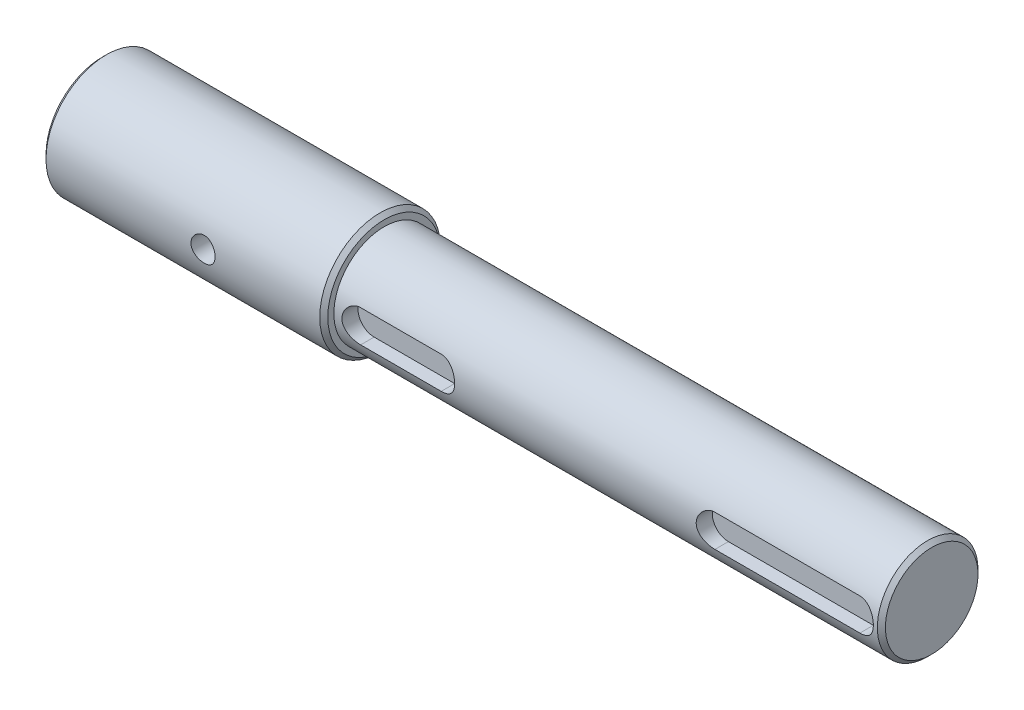
from build123d import *

# Parameters (mm, degrees)
SKETCH_1_R               = 12.5
EXTRUDE_1_DEPTH          = 136
SKETCH_2_R               = 15
EXTRUDE_2_DEPTH          = 70
CHAMFER_1_SIZE           = 1
CUT_EXTRUDE_1_DEPTH      = 4
SKETCH_4_R               = 3
CUT_EXTRUDE_2_DEPTH      = 16
CUT_EXTRUDE_2_DEPTH_BACK = 16


with BuildPart() as part:
    # 草图1 → 凸台-拉伸1 (new body)
    with BuildSketch(Plane(origin=(0, 0, 0), x_dir=(0, 0, -1), z_dir=(1, 0, 0))):
        Circle(SKETCH_1_R)
    extrude(amount=EXTRUDE_1_DEPTH)

    # 草图2 → 凸台-拉伸2 (add)
    with BuildSketch(Plane.ZY):
        Circle(SKETCH_2_R)
    extrude(amount=EXTRUDE_2_DEPTH)

    # 倒角1
    chamfer_1_edges = [part.edges().sort_by_distance(p)[0] for p in [
        (136, 0, 12.5),
        (0, 0, -15),
        (-70, 0, -15),
    ]]
    chamfer(chamfer_1_edges, length=CHAMFER_1_SIZE)

    # 草图3 → 切除-拉伸1 (cut)
    with BuildSketch(Plane.XY.offset(12.5)):
        with BuildLine():
            Line((6, 4), (26, 4))
            ThreePointArc((26, 4), (30, 0), (26, -4))
            Line((26, -4), (6, -4))
            ThreePointArc((6, -4), (2, 0), (6, 4))
        make_face()
        with BuildLine():
            Line((94, 4), (130, 4))
            ThreePointArc((130, 4), (134, 0), (130, -4))
            Line((130, -4), (94, -4))
            ThreePointArc((94, -4), (90, 0), (94, 4))
        make_face()
    extrude(amount=-CUT_EXTRUDE_1_DEPTH, mode=Mode.SUBTRACT)

    # 草图4 → 切除-拉伸2 (cut, two sides)
    with BuildSketch(Plane.XY) as cut_extrude_2_sk:
        with Locations((-30, 0)):
            Circle(SKETCH_4_R)
    extrude(amount=CUT_EXTRUDE_2_DEPTH, mode=Mode.SUBTRACT)
    extrude(cut_extrude_2_sk.sketch, amount=-CUT_EXTRUDE_2_DEPTH_BACK, mode=Mode.SUBTRACT)


solid = part.part
